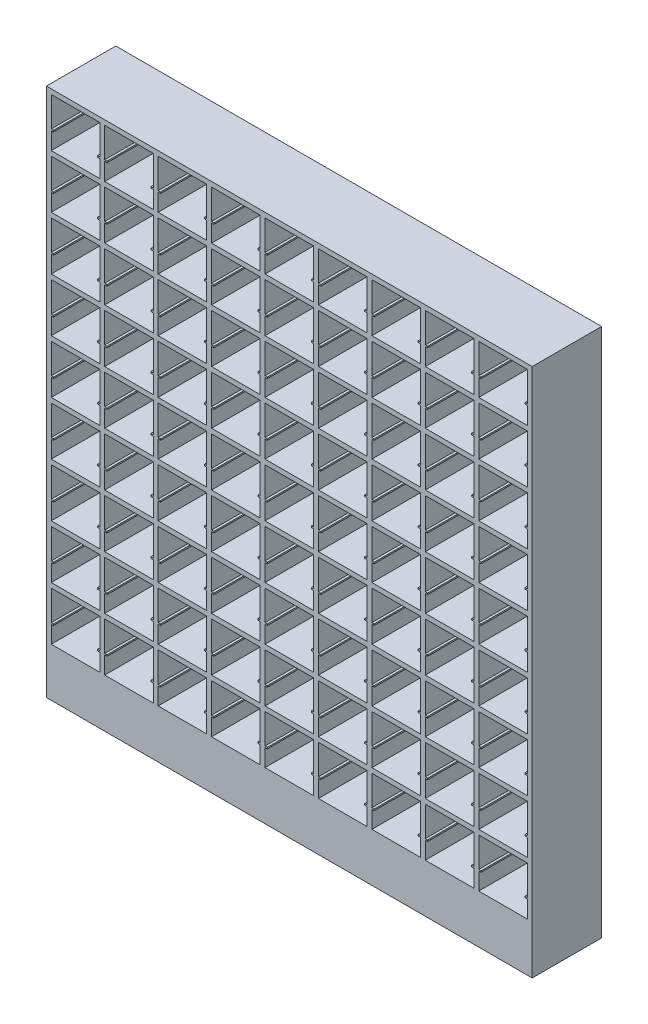
from build123d import *

# Parameters (mm, degrees)
SALIENTE_EXTRUIR4_DEPTH = 500


with BuildPart() as part:
    # Croquis1 → Saliente-Extruir4 (new body)
    with BuildSketch(Plane.XY):
        Polygon((1750, -1750), (1750, 1750), (-1750, 1750), (-1750, -1750), (-1750, -2065), (1750, -2065), align=None)
        Polygon((-1365, 1490), (-1365, 1365), (-1715, 1365), (-1715, 1490), (-1698.33333333, 1490), (-1698.33333333, 1500), (-1715, 1500), (-1715, 1715), (-1365, 1715), (-1365, 1500), (-1381.666666667, 1500), (-1381.666666667, 1490), align=None, mode=Mode.SUBTRACT)
        Polygon((-1330, 1715), (-980, 1715), (-980, 1500), (-996.666666667, 1500), (-996.666666667, 1490), (-980, 1490), (-980, 1365), (-1330, 1365), (-1330, 1490), (-1313.33333333, 1490), (-1313.33333333, 1500), (-1330, 1500), align=None, mode=Mode.SUBTRACT)
        Polygon((-945, 1715), (-595, 1715), (-595, 1500), (-611.666666667, 1500), (-611.666666667, 1490), (-595, 1490), (-595, 1365), (-945, 1365), (-945, 1490), (-928.33333333, 1490), (-928.33333333, 1500), (-945, 1500), align=None, mode=Mode.SUBTRACT)
        Polygon((-560, 1715), (-210, 1715), (-210, 1500), (-226.666666667, 1500), (-226.666666667, 1490), (-210, 1490), (-210, 1365), (-560, 1365), (-560, 1490), (-543.33333333, 1490), (-543.33333333, 1500), (-560, 1500), align=None, mode=Mode.SUBTRACT)
        Polygon((-175, 1715), (175, 1715), (175, 1500), (158.333333333, 1500), (158.333333333, 1490), (175, 1490), (175, 1365), (-175, 1365), (-175, 1490), (-158.33333333, 1490), (-158.33333333, 1500), (-175, 1500), align=None, mode=Mode.SUBTRACT)
        Polygon((210, 1715), (560, 1715), (560, 1500), (543.333333333, 1500), (543.333333333, 1490), (560, 1490), (560, 1365), (210, 1365), (210, 1490), (226.66666667, 1490), (226.66666667, 1500), (210, 1500), align=None, mode=Mode.SUBTRACT)
        Polygon((595, 1715), (945, 1715), (945, 1500), (928.333333333, 1500), (928.333333333, 1490), (945, 1490), (945, 1365), (595, 1365), (595, 1490), (611.66666667, 1490), (611.66666667, 1500), (595, 1500), align=None, mode=Mode.SUBTRACT)
        Polygon((980, 1715), (1330, 1715), (1330, 1500), (1313.333333333, 1500), (1313.333333333, 1490), (1330, 1490), (1330, 1365), (980, 1365), (980, 1490), (996.66666667, 1490), (996.66666667, 1500), (980, 1500), align=None, mode=Mode.SUBTRACT)
        Polygon((1365, 1715), (1715, 1715), (1715, 1500), (1698.333333333, 1500), (1698.333333333, 1490), (1715, 1490), (1715, 1365), (1365, 1365), (1365, 1490), (1381.66666667, 1490), (1381.66666667, 1500), (1365, 1500), align=None, mode=Mode.SUBTRACT)
        Polygon((-1330, 1330), (-980, 1330), (-980, 1115), (-996.666666667, 1115), (-996.666666667, 1105), (-980, 1105), (-980, 980), (-1330, 980), (-1330, 1105), (-1313.33333333, 1105), (-1313.33333333, 1115), (-1330, 1115), align=None, mode=Mode.SUBTRACT)
        Polygon((-945, 1330), (-595, 1330), (-595, 1115), (-611.666666667, 1115), (-611.666666667, 1105), (-595, 1105), (-595, 980), (-945, 980), (-945, 1105), (-928.33333333, 1105), (-928.33333333, 1115), (-945, 1115), align=None, mode=Mode.SUBTRACT)
        Polygon((-560, 1330), (-210, 1330), (-210, 1115), (-226.666666667, 1115), (-226.666666667, 1105), (-210, 1105), (-210, 980), (-560, 980), (-560, 1105), (-543.33333333, 1105), (-543.33333333, 1115), (-560, 1115), align=None, mode=Mode.SUBTRACT)
        Polygon((-175, 1330), (175, 1330), (175, 1115), (158.333333333, 1115), (158.333333333, 1105), (175, 1105), (175, 980), (-175, 980), (-175, 1105), (-158.33333333, 1105), (-158.33333333, 1115), (-175, 1115), align=None, mode=Mode.SUBTRACT)
        Polygon((210, 1330), (560, 1330), (560, 1115), (543.333333333, 1115), (543.333333333, 1105), (560, 1105), (560, 980), (210, 980), (210, 1105), (226.66666667, 1105), (226.66666667, 1115), (210, 1115), align=None, mode=Mode.SUBTRACT)
        Polygon((595, 1330), (945, 1330), (945, 1115), (928.333333333, 1115), (928.333333333, 1105), (945, 1105), (945, 980), (595, 980), (595, 1105), (611.66666667, 1105), (611.66666667, 1115), (595, 1115), align=None, mode=Mode.SUBTRACT)
        Polygon((980, 1330), (1330, 1330), (1330, 1115), (1313.333333333, 1115), (1313.333333333, 1105), (1330, 1105), (1330, 980), (980, 980), (980, 1105), (996.66666667, 1105), (996.66666667, 1115), (980, 1115), align=None, mode=Mode.SUBTRACT)
        Polygon((1365, 1330), (1715, 1330), (1715, 1115), (1698.333333333, 1115), (1698.333333333, 1105), (1715, 1105), (1715, 980), (1365, 980), (1365, 1105), (1381.66666667, 1105), (1381.66666667, 1115), (1365, 1115), align=None, mode=Mode.SUBTRACT)
        Polygon((-1330, 945), (-980, 945), (-980, 730), (-996.666666667, 730), (-996.666666667, 720), (-980, 720), (-980, 595), (-1330, 595), (-1330, 720), (-1313.33333333, 720), (-1313.33333333, 730), (-1330, 730), align=None, mode=Mode.SUBTRACT)
        Polygon((-945, 945), (-595, 945), (-595, 730), (-611.666666667, 730), (-611.666666667, 720), (-595, 720), (-595, 595), (-945, 595), (-945, 720), (-928.33333333, 720), (-928.33333333, 730), (-945, 730), align=None, mode=Mode.SUBTRACT)
        Polygon((-560, 945), (-210, 945), (-210, 730), (-226.666666667, 730), (-226.666666667, 720), (-210, 720), (-210, 595), (-560, 595), (-560, 720), (-543.33333333, 720), (-543.33333333, 730), (-560, 730), align=None, mode=Mode.SUBTRACT)
        Polygon((-175, 945), (175, 945), (175, 730), (158.333333333, 730), (158.333333333, 720), (175, 720), (175, 595), (-175, 595), (-175, 720), (-158.33333333, 720), (-158.33333333, 730), (-175, 730), align=None, mode=Mode.SUBTRACT)
        Polygon((210, 945), (560, 945), (560, 730), (543.333333333, 730), (543.333333333, 720), (560, 720), (560, 595), (210, 595), (210, 720), (226.66666667, 720), (226.66666667, 730), (210, 730), align=None, mode=Mode.SUBTRACT)
        Polygon((595, 945), (945, 945), (945, 730), (928.333333333, 730), (928.333333333, 720), (945, 720), (945, 595), (595, 595), (595, 720), (611.66666667, 720), (611.66666667, 730), (595, 730), align=None, mode=Mode.SUBTRACT)
        Polygon((980, 945), (1330, 945), (1330, 730), (1313.333333333, 730), (1313.333333333, 720), (1330, 720), (1330, 595), (980, 595), (980, 720), (996.66666667, 720), (996.66666667, 730), (980, 730), align=None, mode=Mode.SUBTRACT)
        Polygon((1365, 945), (1715, 945), (1715, 730), (1698.333333333, 730), (1698.333333333, 720), (1715, 720), (1715, 595), (1365, 595), (1365, 720), (1381.66666667, 720), (1381.66666667, 730), (1365, 730), align=None, mode=Mode.SUBTRACT)
        Polygon((-1330, 560), (-980, 560), (-980, 345), (-996.666666667, 345), (-996.666666667, 335), (-980, 335), (-980, 210), (-1330, 210), (-1330, 335), (-1313.33333333, 335), (-1313.33333333, 345), (-1330, 345), align=None, mode=Mode.SUBTRACT)
        Polygon((-945, 560), (-595, 560), (-595, 345), (-611.666666667, 345), (-611.666666667, 335), (-595, 335), (-595, 210), (-945, 210), (-945, 335), (-928.33333333, 335), (-928.33333333, 345), (-945, 345), align=None, mode=Mode.SUBTRACT)
        Polygon((-560, 560), (-210, 560), (-210, 345), (-226.666666667, 345), (-226.666666667, 335), (-210, 335), (-210, 210), (-560, 210), (-560, 335), (-543.33333333, 335), (-543.33333333, 345), (-560, 345), align=None, mode=Mode.SUBTRACT)
        Polygon((-175, 560), (175, 560), (175, 345), (158.333333333, 345), (158.333333333, 335), (175, 335), (175, 210), (-175, 210), (-175, 335), (-158.33333333, 335), (-158.33333333, 345), (-175, 345), align=None, mode=Mode.SUBTRACT)
        Polygon((210, 560), (560, 560), (560, 345), (543.333333333, 345), (543.333333333, 335), (560, 335), (560, 210), (210, 210), (210, 335), (226.66666667, 335), (226.66666667, 345), (210, 345), align=None, mode=Mode.SUBTRACT)
        Polygon((595, 560), (945, 560), (945, 345), (928.333333333, 345), (928.333333333, 335), (945, 335), (945, 210), (595, 210), (595, 335), (611.66666667, 335), (611.66666667, 345), (595, 345), align=None, mode=Mode.SUBTRACT)
        Polygon((980, 560), (1330, 560), (1330, 345), (1313.333333333, 345), (1313.333333333, 335), (1330, 335), (1330, 210), (980, 210), (980, 335), (996.66666667, 335), (996.66666667, 345), (980, 345), align=None, mode=Mode.SUBTRACT)
        Polygon((1365, 560), (1715, 560), (1715, 345), (1698.333333333, 345), (1698.333333333, 335), (1715, 335), (1715, 210), (1365, 210), (1365, 335), (1381.66666667, 335), (1381.66666667, 345), (1365, 345), align=None, mode=Mode.SUBTRACT)
        Polygon((-1330, 175), (-980, 175), (-980, -40), (-996.666666667, -40), (-996.666666667, -50), (-980, -50), (-980, -175), (-1330, -175), (-1330, -50), (-1313.33333333, -50), (-1313.33333333, -40), (-1330, -40), align=None, mode=Mode.SUBTRACT)
        Polygon((-945, 175), (-595, 175), (-595, -40), (-611.666666667, -40), (-611.666666667, -50), (-595, -50), (-595, -175), (-945, -175), (-945, -50), (-928.33333333, -50), (-928.33333333, -40), (-945, -40), align=None, mode=Mode.SUBTRACT)
        Polygon((-560, 175), (-210, 175), (-210, -40), (-226.666666667, -40), (-226.666666667, -50), (-210, -50), (-210, -175), (-560, -175), (-560, -50), (-543.33333333, -50), (-543.33333333, -40), (-560, -40), align=None, mode=Mode.SUBTRACT)
        Polygon((-175, 175), (175, 175), (175, -40), (158.333333333, -40), (158.333333333, -50), (175, -50), (175, -175), (-175, -175), (-175, -50), (-158.33333333, -50), (-158.33333333, -40), (-175, -40), align=None, mode=Mode.SUBTRACT)
        Polygon((210, 175), (560, 175), (560, -40), (543.333333333, -40), (543.333333333, -50), (560, -50), (560, -175), (210, -175), (210, -50), (226.66666667, -50), (226.66666667, -40), (210, -40), align=None, mode=Mode.SUBTRACT)
        Polygon((595, 175), (945, 175), (945, -40), (928.333333333, -40), (928.333333333, -50), (945, -50), (945, -175), (595, -175), (595, -50), (611.66666667, -50), (611.66666667, -40), (595, -40), align=None, mode=Mode.SUBTRACT)
        Polygon((980, 175), (1330, 175), (1330, -40), (1313.333333333, -40), (1313.333333333, -50), (1330, -50), (1330, -175), (980, -175), (980, -50), (996.66666667, -50), (996.66666667, -40), (980, -40), align=None, mode=Mode.SUBTRACT)
        Polygon((1365, 175), (1715, 175), (1715, -40), (1698.333333333, -40), (1698.333333333, -50), (1715, -50), (1715, -175), (1365, -175), (1365, -50), (1381.66666667, -50), (1381.66666667, -40), (1365, -40), align=None, mode=Mode.SUBTRACT)
        Polygon((-1330, -210), (-980, -210), (-980, -425), (-996.666666667, -425), (-996.666666667, -435), (-980, -435), (-980, -560), (-1330, -560), (-1330, -435), (-1313.33333333, -435), (-1313.33333333, -425), (-1330, -425), align=None, mode=Mode.SUBTRACT)
        Polygon((-945, -210), (-595, -210), (-595, -425), (-611.666666667, -425), (-611.666666667, -435), (-595, -435), (-595, -560), (-945, -560), (-945, -435), (-928.33333333, -435), (-928.33333333, -425), (-945, -425), align=None, mode=Mode.SUBTRACT)
        Polygon((-560, -210), (-210, -210), (-210, -425), (-226.666666667, -425), (-226.666666667, -435), (-210, -435), (-210, -560), (-560, -560), (-560, -435), (-543.33333333, -435), (-543.33333333, -425), (-560, -425), align=None, mode=Mode.SUBTRACT)
        Polygon((-175, -210), (175, -210), (175, -425), (158.333333333, -425), (158.333333333, -435), (175, -435), (175, -560), (-175, -560), (-175, -435), (-158.33333333, -435), (-158.33333333, -425), (-175, -425), align=None, mode=Mode.SUBTRACT)
        Polygon((210, -210), (560, -210), (560, -425), (543.333333333, -425), (543.333333333, -435), (560, -435), (560, -560), (210, -560), (210, -435), (226.66666667, -435), (226.66666667, -425), (210, -425), align=None, mode=Mode.SUBTRACT)
        Polygon((595, -210), (945, -210), (945, -425), (928.333333333, -425), (928.333333333, -435), (945, -435), (945, -560), (595, -560), (595, -435), (611.66666667, -435), (611.66666667, -425), (595, -425), align=None, mode=Mode.SUBTRACT)
        Polygon((980, -210), (1330, -210), (1330, -425), (1313.333333333, -425), (1313.333333333, -435), (1330, -435), (1330, -560), (980, -560), (980, -435), (996.66666667, -435), (996.66666667, -425), (980, -425), align=None, mode=Mode.SUBTRACT)
        Polygon((1365, -210), (1715, -210), (1715, -425), (1698.333333333, -425), (1698.333333333, -435), (1715, -435), (1715, -560), (1365, -560), (1365, -435), (1381.66666667, -435), (1381.66666667, -425), (1365, -425), align=None, mode=Mode.SUBTRACT)
        Polygon((-1330, -595), (-980, -595), (-980, -810), (-996.666666667, -810), (-996.666666667, -820), (-980, -820), (-980, -945), (-1330, -945), (-1330, -820), (-1313.33333333, -820), (-1313.33333333, -810), (-1330, -810), align=None, mode=Mode.SUBTRACT)
        Polygon((-945, -595), (-595, -595), (-595, -810), (-611.666666667, -810), (-611.666666667, -820), (-595, -820), (-595, -945), (-945, -945), (-945, -820), (-928.33333333, -820), (-928.33333333, -810), (-945, -810), align=None, mode=Mode.SUBTRACT)
        Polygon((-560, -595), (-210, -595), (-210, -810), (-226.666666667, -810), (-226.666666667, -820), (-210, -820), (-210, -945), (-560, -945), (-560, -820), (-543.33333333, -820), (-543.33333333, -810), (-560, -810), align=None, mode=Mode.SUBTRACT)
        Polygon((-175, -595), (175, -595), (175, -810), (158.333333333, -810), (158.333333333, -820), (175, -820), (175, -945), (-175, -945), (-175, -820), (-158.33333333, -820), (-158.33333333, -810), (-175, -810), align=None, mode=Mode.SUBTRACT)
        Polygon((210, -595), (560, -595), (560, -810), (543.333333333, -810), (543.333333333, -820), (560, -820), (560, -945), (210, -945), (210, -820), (226.66666667, -820), (226.66666667, -810), (210, -810), align=None, mode=Mode.SUBTRACT)
        Polygon((595, -595), (945, -595), (945, -810), (928.333333333, -810), (928.333333333, -820), (945, -820), (945, -945), (595, -945), (595, -820), (611.66666667, -820), (611.66666667, -810), (595, -810), align=None, mode=Mode.SUBTRACT)
        Polygon((980, -595), (1330, -595), (1330, -810), (1313.333333333, -810), (1313.333333333, -820), (1330, -820), (1330, -945), (980, -945), (980, -820), (996.66666667, -820), (996.66666667, -810), (980, -810), align=None, mode=Mode.SUBTRACT)
        Polygon((1365, -595), (1715, -595), (1715, -810), (1698.333333333, -810), (1698.333333333, -820), (1715, -820), (1715, -945), (1365, -945), (1365, -820), (1381.66666667, -820), (1381.66666667, -810), (1365, -810), align=None, mode=Mode.SUBTRACT)
        Polygon((-1330, -980), (-980, -980), (-980, -1195), (-996.666666667, -1195), (-996.666666667, -1205), (-980, -1205), (-980, -1330), (-1330, -1330), (-1330, -1205), (-1313.33333333, -1205), (-1313.33333333, -1195), (-1330, -1195), align=None, mode=Mode.SUBTRACT)
        Polygon((-945, -980), (-595, -980), (-595, -1195), (-611.666666667, -1195), (-611.666666667, -1205), (-595, -1205), (-595, -1330), (-945, -1330), (-945, -1205), (-928.33333333, -1205), (-928.33333333, -1195), (-945, -1195), align=None, mode=Mode.SUBTRACT)
        Polygon((-560, -980), (-210, -980), (-210, -1195), (-226.666666667, -1195), (-226.666666667, -1205), (-210, -1205), (-210, -1330), (-560, -1330), (-560, -1205), (-543.33333333, -1205), (-543.33333333, -1195), (-560, -1195), align=None, mode=Mode.SUBTRACT)
        Polygon((-175, -980), (175, -980), (175, -1195), (158.333333333, -1195), (158.333333333, -1205), (175, -1205), (175, -1330), (-175, -1330), (-175, -1205), (-158.33333333, -1205), (-158.33333333, -1195), (-175, -1195), align=None, mode=Mode.SUBTRACT)
        Polygon((210, -980), (560, -980), (560, -1195), (543.333333333, -1195), (543.333333333, -1205), (560, -1205), (560, -1330), (210, -1330), (210, -1205), (226.66666667, -1205), (226.66666667, -1195), (210, -1195), align=None, mode=Mode.SUBTRACT)
        Polygon((595, -980), (945, -980), (945, -1195), (928.333333333, -1195), (928.333333333, -1205), (945, -1205), (945, -1330), (595, -1330), (595, -1205), (611.66666667, -1205), (611.66666667, -1195), (595, -1195), align=None, mode=Mode.SUBTRACT)
        Polygon((980, -980), (1330, -980), (1330, -1195), (1313.333333333, -1195), (1313.333333333, -1205), (1330, -1205), (1330, -1330), (980, -1330), (980, -1205), (996.66666667, -1205), (996.66666667, -1195), (980, -1195), align=None, mode=Mode.SUBTRACT)
        Polygon((1365, -980), (1715, -980), (1715, -1195), (1698.333333333, -1195), (1698.333333333, -1205), (1715, -1205), (1715, -1330), (1365, -1330), (1365, -1205), (1381.66666667, -1205), (1381.66666667, -1195), (1365, -1195), align=None, mode=Mode.SUBTRACT)
        Polygon((-1330, -1365), (-980, -1365), (-980, -1580), (-996.666666667, -1580), (-996.666666667, -1590), (-980, -1590), (-980, -1715), (-1330, -1715), (-1330, -1590), (-1313.33333333, -1590), (-1313.33333333, -1580), (-1330, -1580), align=None, mode=Mode.SUBTRACT)
        Polygon((-945, -1365), (-595, -1365), (-595, -1580), (-611.666666667, -1580), (-611.666666667, -1590), (-595, -1590), (-595, -1715), (-945, -1715), (-945, -1590), (-928.33333333, -1590), (-928.33333333, -1580), (-945, -1580), align=None, mode=Mode.SUBTRACT)
        Polygon((-560, -1365), (-210, -1365), (-210, -1580), (-226.666666667, -1580), (-226.666666667, -1590), (-210, -1590), (-210, -1715), (-560, -1715), (-560, -1590), (-543.33333333, -1590), (-543.33333333, -1580), (-560, -1580), align=None, mode=Mode.SUBTRACT)
        Polygon((-175, -1365), (175, -1365), (175, -1580), (158.333333333, -1580), (158.333333333, -1590), (175, -1590), (175, -1715), (-175, -1715), (-175, -1590), (-158.33333333, -1590), (-158.33333333, -1580), (-175, -1580), align=None, mode=Mode.SUBTRACT)
        Polygon((210, -1365), (560, -1365), (560, -1580), (543.333333333, -1580), (543.333333333, -1590), (560, -1590), (560, -1715), (210, -1715), (210, -1590), (226.66666667, -1590), (226.66666667, -1580), (210, -1580), align=None, mode=Mode.SUBTRACT)
        Polygon((595, -1365), (945, -1365), (945, -1580), (928.333333333, -1580), (928.333333333, -1590), (945, -1590), (945, -1715), (595, -1715), (595, -1590), (611.66666667, -1590), (611.66666667, -1580), (595, -1580), align=None, mode=Mode.SUBTRACT)
        Polygon((980, -1365), (1330, -1365), (1330, -1580), (1313.333333333, -1580), (1313.333333333, -1590), (1330, -1590), (1330, -1715), (980, -1715), (980, -1590), (996.66666667, -1590), (996.66666667, -1580), (980, -1580), align=None, mode=Mode.SUBTRACT)
        Polygon((1365, -1365), (1715, -1365), (1715, -1580), (1698.333333333, -1580), (1698.333333333, -1590), (1715, -1590), (1715, -1715), (1365, -1715), (1365, -1590), (1381.66666667, -1590), (1381.66666667, -1580), (1365, -1580), align=None, mode=Mode.SUBTRACT)
        Polygon((-1715, 1330), (-1365, 1330), (-1365, 1115), (-1381.666666667, 1115), (-1381.666666667, 1105), (-1365, 1105), (-1365, 980), (-1715, 980), (-1715, 1105), (-1698.33333333, 1105), (-1698.33333333, 1115), (-1715, 1115), align=None, mode=Mode.SUBTRACT)
        Polygon((-1715, 945), (-1365, 945), (-1365, 730), (-1381.666666667, 730), (-1381.666666667, 720), (-1365, 720), (-1365, 595), (-1715, 595), (-1715, 720), (-1698.33333333, 720), (-1698.33333333, 730), (-1715, 730), align=None, mode=Mode.SUBTRACT)
        Polygon((-1715, 560), (-1365, 560), (-1365, 345), (-1381.666666667, 345), (-1381.666666667, 335), (-1365, 335), (-1365, 210), (-1715, 210), (-1715, 335), (-1698.33333333, 335), (-1698.33333333, 345), (-1715, 345), align=None, mode=Mode.SUBTRACT)
        Polygon((-1715, 175), (-1365, 175), (-1365, -40), (-1381.666666667, -40), (-1381.666666667, -50), (-1365, -50), (-1365, -175), (-1715, -175), (-1715, -50), (-1698.33333333, -50), (-1698.33333333, -40), (-1715, -40), align=None, mode=Mode.SUBTRACT)
        Polygon((-1715, -210), (-1365, -210), (-1365, -425), (-1381.666666667, -425), (-1381.666666667, -435), (-1365, -435), (-1365, -560), (-1715, -560), (-1715, -435), (-1698.33333333, -435), (-1698.33333333, -425), (-1715, -425), align=None, mode=Mode.SUBTRACT)
        Polygon((-1715, -595), (-1365, -595), (-1365, -810), (-1381.666666667, -810), (-1381.666666667, -820), (-1365, -820), (-1365, -945), (-1715, -945), (-1715, -820), (-1698.33333333, -820), (-1698.33333333, -810), (-1715, -810), align=None, mode=Mode.SUBTRACT)
        Polygon((-1715, -980), (-1365, -980), (-1365, -1195), (-1381.666666667, -1195), (-1381.666666667, -1205), (-1365, -1205), (-1365, -1330), (-1715, -1330), (-1715, -1205), (-1698.33333333, -1205), (-1698.33333333, -1195), (-1715, -1195), align=None, mode=Mode.SUBTRACT)
        Polygon((-1715, -1365), (-1365, -1365), (-1365, -1580), (-1381.666666667, -1580), (-1381.666666667, -1590), (-1365, -1590), (-1365, -1715), (-1715, -1715), (-1715, -1590), (-1698.33333333, -1590), (-1698.33333333, -1580), (-1715, -1580), align=None, mode=Mode.SUBTRACT)
    extrude(amount=SALIENTE_EXTRUIR4_DEPTH)


solid = part.part
